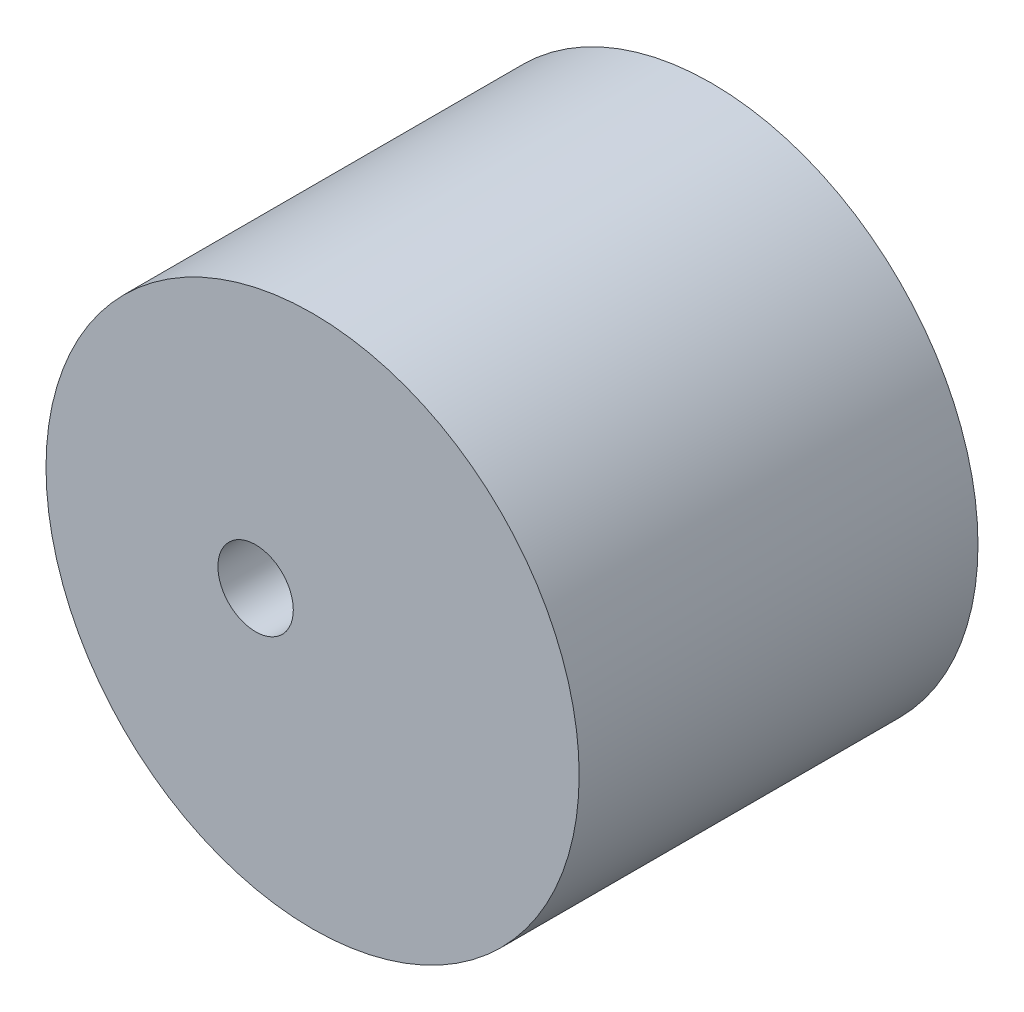
from build123d import *

# Parameters (mm, degrees)
SKETCH11_R           = 23.39375
SKETCH11_R_2         = 3.3085
BOSS_EXTRUDE13_DEPTH = 35


with BuildPart() as part:
    # Sketch11 → Boss-Extrude13 (new body)
    with BuildSketch(Plane.XY):
        Circle(SKETCH11_R)
        with Locations((-5, 0)):
            Circle(SKETCH11_R_2, mode=Mode.SUBTRACT)
    extrude(amount=BOSS_EXTRUDE13_DEPTH)


solid = part.part
